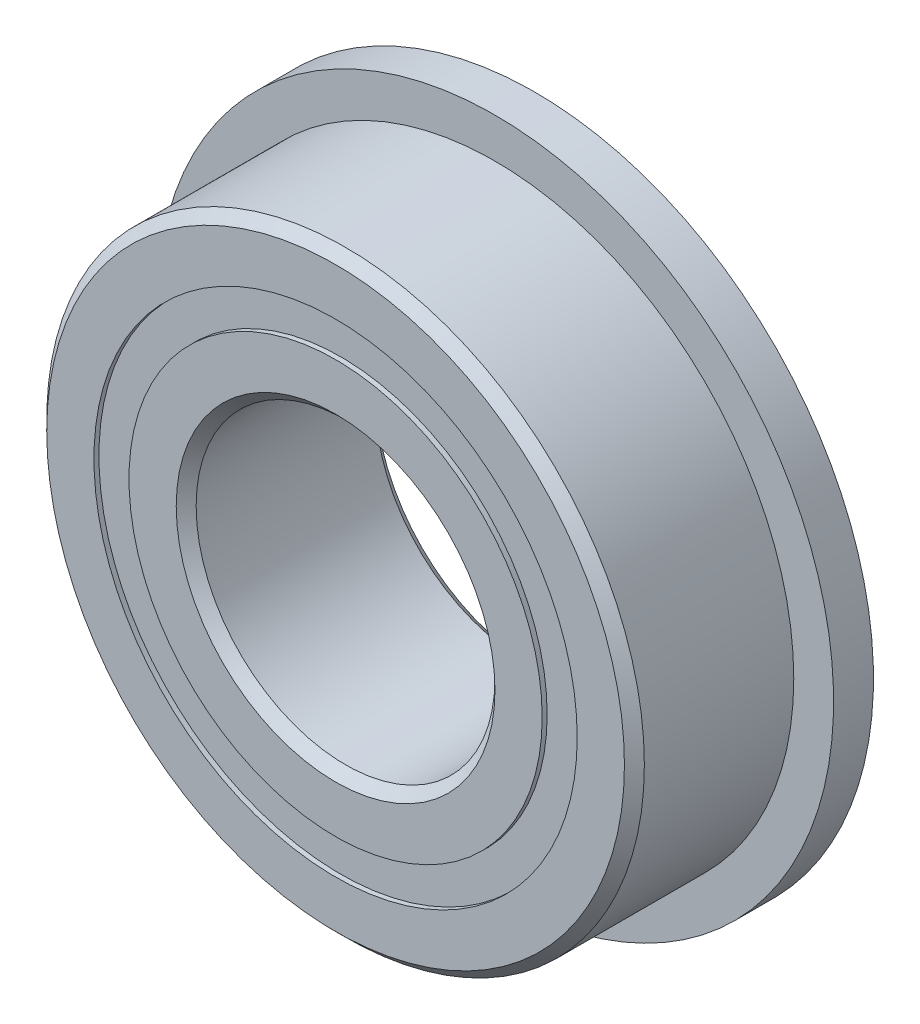
from build123d import *

# Parameters (mm, degrees)
CIRPATTERN1_COUNT = 12
SKETCH5_W         = 0.944081583
SKETCH5_H         = 0.703296704
SKETCH6_W         = 0.8
SKETCH6_H         = 1.948351648


with BuildPart() as part:
    # Sketch1 → Revolve1 (revolve)
    with BuildSketch(Plane(origin=(0, 0, 0), x_dir=(0, 0, -1), z_dir=(1, 0, 0))):
        with BuildLine():
            Line((1.8, 6), (-1.8, 6))
            Line((-1.8, 6), (-2, 5.8))
            Line((-2, 5.8), (-2, 4.851648352))
            Line((-2, 4.851648352), (-0.888888889, 4.851648352))
            ThreePointArc((-0.888888889, 4.851648352), (0, 5.455918417), (0.888888889, 4.851648352))
            Line((0.888888889, 4.851648352), (2, 4.851648352))
            Line((2, 4.851648352), (2, 5.8))
            Line((2, 5.8), (1.8, 6))
        make_face()
    revolve(axis=Axis((0, 0, 2), (0, 0, -1)))

    # Sketch6 → Revolve6 (revolve)
    with BuildSketch(Plane(origin=(0, 0, 0), x_dir=(0, 0, -1), z_dir=(1, 0, 0))):
        with Locations((1.6, 5.825824176)):
            Rectangle(SKETCH6_W, SKETCH6_H)
    revolve(axis=Axis((0, 0, -2), (0, 0, 1)))


with BuildPart() as body_2:
    # Sketch3 → Revolve3 (revolve)
    with BuildSketch(Plane(origin=(0, 0, 0), x_dir=(0, 0, -1), z_dir=(1, 0, 0))):
        with BuildLine():
            Line((-2, 4.148351648), (-0.888888889, 4.148351648))
            ThreePointArc((-0.888888889, 4.148351648), (0, 3.544081583), (0.888888889, 4.148351648))
            Line((0.888888889, 4.148351648), (2, 4.148351648))
            Line((2, 4.148351648), (2, 3.2))
            Line((2, 3.2), (1.8, 3))
            Line((1.8, 3), (-1.8, 3))
            Line((-1.8, 3), (-2, 3.2))
            Line((-2, 3.2), (-2, 4.148351648))
        make_face()
    revolve(axis=Axis((0, 0, 2), (0, 0, -1)))


with BuildPart() as body_3:
    # Sketch4 → Revolve4 (revolve)
    with BuildSketch(Plane(origin=(0, 0, 0), x_dir=(0, 0, -1), z_dir=(1, 0, 0))):
        with BuildLine():
            Line((-0.955918417, 4.5), (0.955918417, 4.5))
            ThreePointArc((0.955918417, 4.5), (0, 5.455918417), (-0.955918417, 4.5))
        make_face()
    revolve(axis=Axis((0, 4.5, 0.955918417), (0, 0, -1)))


with BuildPart() as cirpattern1_1:
    # CirPattern1: pattern copy
    add(body_3.part.rotate(Axis((0, 0, -2), (0, 0, 1)), 1 * 360 / CIRPATTERN1_COUNT))


with BuildPart() as cirpattern1_2:
    # CirPattern1: pattern copy
    add(body_3.part.rotate(Axis((0, 0, -2), (0, 0, 1)), 2 * 360 / CIRPATTERN1_COUNT))


with BuildPart() as cirpattern1_3:
    # CirPattern1: pattern copy
    add(body_3.part.rotate(Axis((0, 0, -2), (0, 0, 1)), 3 * 360 / CIRPATTERN1_COUNT))


with BuildPart() as cirpattern1_4:
    # CirPattern1: pattern copy
    add(body_3.part.rotate(Axis((0, 0, -2), (0, 0, 1)), 4 * 360 / CIRPATTERN1_COUNT))


with BuildPart() as cirpattern1_5:
    # CirPattern1: pattern copy
    add(body_3.part.rotate(Axis((0, 0, -2), (0, 0, 1)), 5 * 360 / CIRPATTERN1_COUNT))


with BuildPart() as cirpattern1_6:
    # CirPattern1: pattern copy
    add(body_3.part.rotate(Axis((0, 0, -2), (0, 0, 1)), 6 * 360 / CIRPATTERN1_COUNT))


with BuildPart() as cirpattern1_7:
    # CirPattern1: pattern copy
    add(body_3.part.rotate(Axis((0, 0, -2), (0, 0, 1)), 7 * 360 / CIRPATTERN1_COUNT))


with BuildPart() as cirpattern1_8:
    # CirPattern1: pattern copy
    add(body_3.part.rotate(Axis((0, 0, -2), (0, 0, 1)), 8 * 360 / CIRPATTERN1_COUNT))


with BuildPart() as cirpattern1_9:
    # CirPattern1: pattern copy
    add(body_3.part.rotate(Axis((0, 0, -2), (0, 0, 1)), 9 * 360 / CIRPATTERN1_COUNT))


with BuildPart() as cirpattern1_10:
    # CirPattern1: pattern copy
    add(body_3.part.rotate(Axis((0, 0, -2), (0, 0, 1)), 10 * 360 / CIRPATTERN1_COUNT))


with BuildPart() as cirpattern1_11:
    # CirPattern1: pattern copy
    add(body_3.part.rotate(Axis((0, 0, -2), (0, 0, 1)), 11 * 360 / CIRPATTERN1_COUNT))


with BuildPart() as body_15:
    # Sketch5 → Revolve5 (revolve)
    with BuildSketch(Plane(origin=(0, 0, 0), x_dir=(0, 0, -1), z_dir=(1, 0, 0))):
        with Locations((-1.427959209, 4.5)):
            Rectangle(SKETCH5_W, SKETCH5_H)
        with Locations((1.427959209, 4.5)):
            Rectangle(SKETCH5_W, SKETCH5_H)
    revolve(axis=Axis((0, 0, 2), (0, 0, -1)))


solid = Compound([part.part, body_2.part, body_3.part, cirpattern1_1.part, cirpattern1_2.part, cirpattern1_3.part, cirpattern1_4.part, cirpattern1_5.part, cirpattern1_6.part, cirpattern1_7.part, cirpattern1_8.part, cirpattern1_9.part, cirpattern1_10.part, cirpattern1_11.part, body_15.part])
